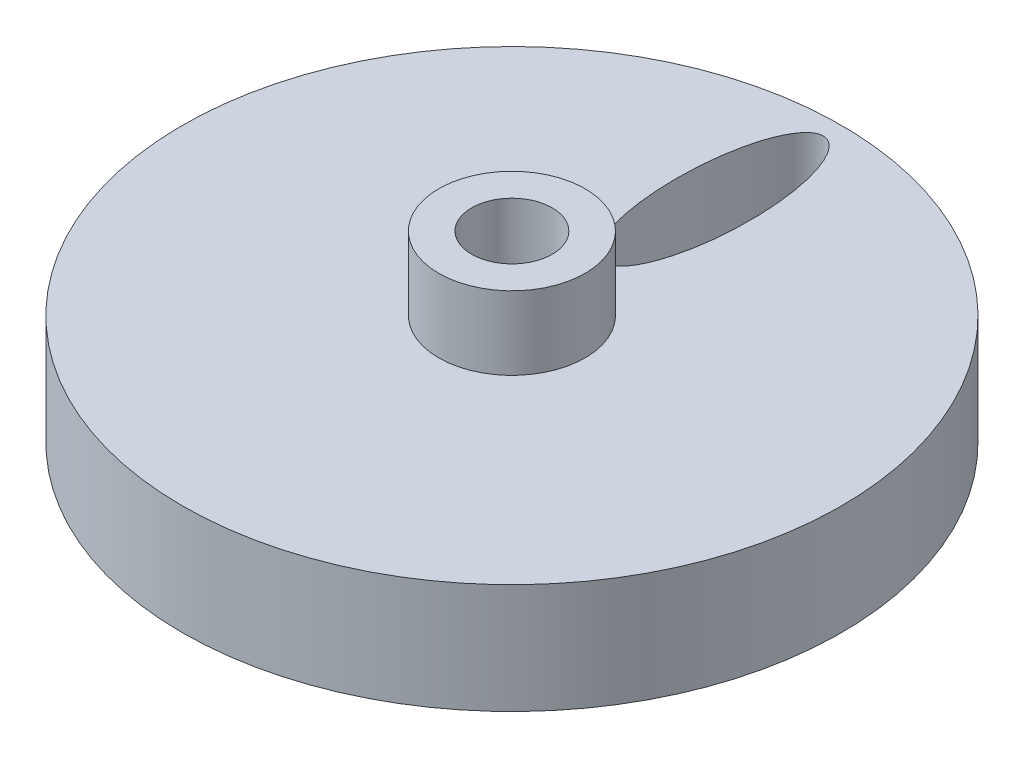
from build123d import *

# Parameters (mm, degrees)
SKETCH1_R           = 9
BOSS_EXTRUDE1_DEPTH = 3
SKETCH2_R           = 2
BOSS_EXTRUDE2_DEPTH = 2
SKETCH3_R           = 1.1
CUT_EXTRUDE1_DEPTH  = 2
SKETCH4_RX          = 3
SKETCH4_RY          = 1
CUT_EXTRUDE2_DEPTH  = 3


with BuildPart() as part:
    # Sketch1 → Boss-Extrude1 (new body)
    with BuildSketch(Plane(origin=(0, 0, 0), x_dir=(1, 0, 0), z_dir=(0, 1, 0))):
        Circle(SKETCH1_R)
    extrude(amount=BOSS_EXTRUDE1_DEPTH)

    # Sketch2 → Boss-Extrude2 (add)
    with BuildSketch(Plane(origin=(0, 3, 0), x_dir=(1, 0, 0), z_dir=(0, 1, 0))):
        Circle(SKETCH2_R)
    extrude(amount=BOSS_EXTRUDE2_DEPTH)

    # Sketch3 → Cut-Extrude1 (cut)
    with BuildSketch(Plane(origin=(0, 5, 0), x_dir=(1, 0, 0), z_dir=(0, 1, 0))):
        Circle(SKETCH3_R)
    extrude(amount=-CUT_EXTRUDE1_DEPTH, mode=Mode.SUBTRACT)

    # Sketch4 → Cut-Extrude2 (cut)
    with BuildSketch(Plane(origin=(0, 3, 0), x_dir=(1, 0, 0), z_dir=(0, 1, 0))):
        with Locations(Location((0, 5.49925853), (0, 0, 90))):
            Ellipse(SKETCH4_RX, SKETCH4_RY)
    extrude(amount=-CUT_EXTRUDE2_DEPTH, mode=Mode.SUBTRACT)


solid = part.part
